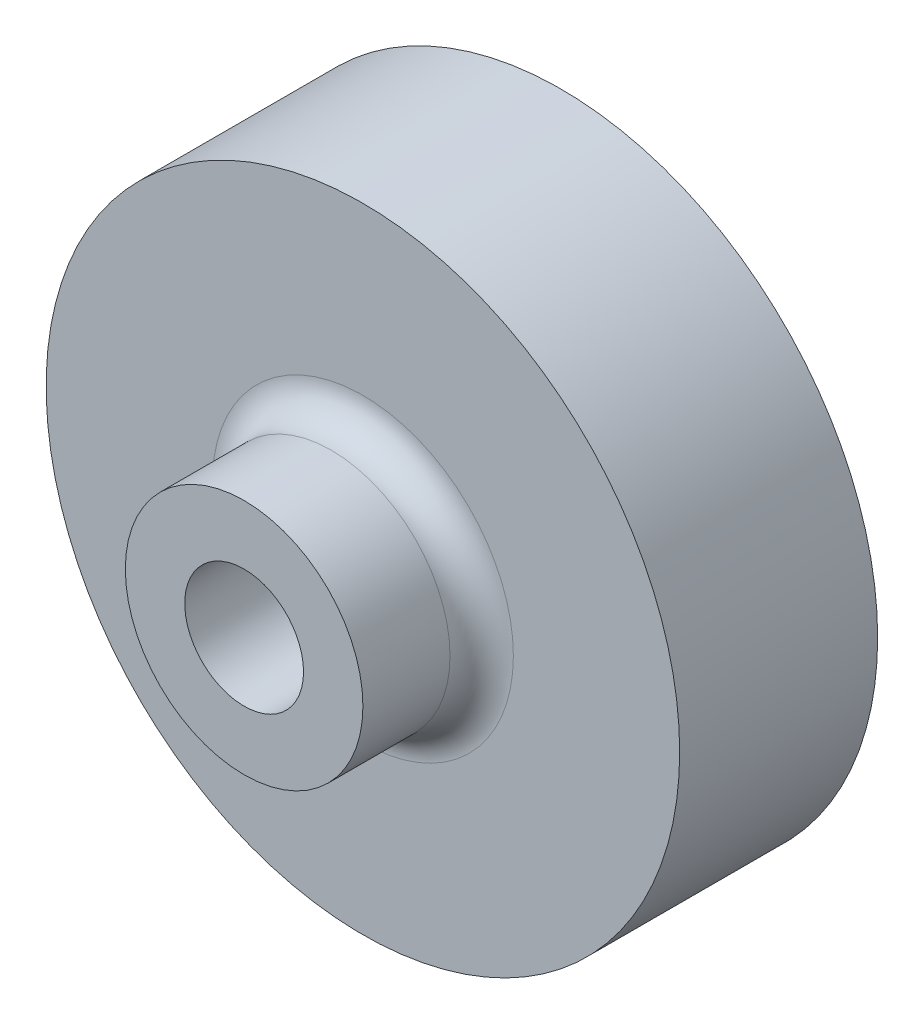
from build123d import *

# Parameters (mm, degrees)
SKETCH2_R           = 25.4
BOSS_EXTRUDE1_DEPTH = 15.875
SKETCH3_R           = 9.525
SKETCH3_R_2         = 4.7625
BOSS_EXTRUDE2_DEPTH = 9.525
SKETCH4_R           = 4.7625
CUT_EXTRUDE2_DEPTH  = 24.511
BOSS_EXTRUDE3_DEPTH = 3.175
FILLET1_R           = 2.54


with BuildPart() as part:
    # Sketch2 → Boss-Extrude1 (new body)
    with BuildSketch(Plane.XY):
        Circle(SKETCH2_R)
    extrude(amount=BOSS_EXTRUDE1_DEPTH)

    # Sketch3 → Boss-Extrude2 (add)
    with BuildSketch(Plane.XY.offset(15.875)):
        Circle(SKETCH3_R)
        Circle(SKETCH3_R_2, mode=Mode.SUBTRACT)
    extrude(amount=BOSS_EXTRUDE2_DEPTH)

    # Sketch4 → Cut-Extrude2 (cut)
    with BuildSketch(Plane.XY.offset(15.875)):
        Circle(SKETCH4_R)
    extrude(amount=-CUT_EXTRUDE2_DEPTH, mode=Mode.SUBTRACT)

    # Sketch5 → Boss-Extrude3 (add)
    with BuildSketch(Plane(origin=(0, 0, 0), x_dir=(-1, 0, 0), z_dir=(0, 0, -1))):
        Polygon((0, 4.7625), (1.27, 4.7625), (1.27, 0), (1.27, -4.7625), (0, -4.7625), (-1.27, -4.7625), (-1.27, 0), (-1.27, 4.7625), align=None)
    extrude(amount=-BOSS_EXTRUDE3_DEPTH)

    # Fillet1
    fillet1_edges = [part.edges().sort_by_distance(p)[0] for p in [
        (-9.525, 0, 15.875),
    ]]
    fillet(fillet1_edges, radius=FILLET1_R)


solid = part.part
